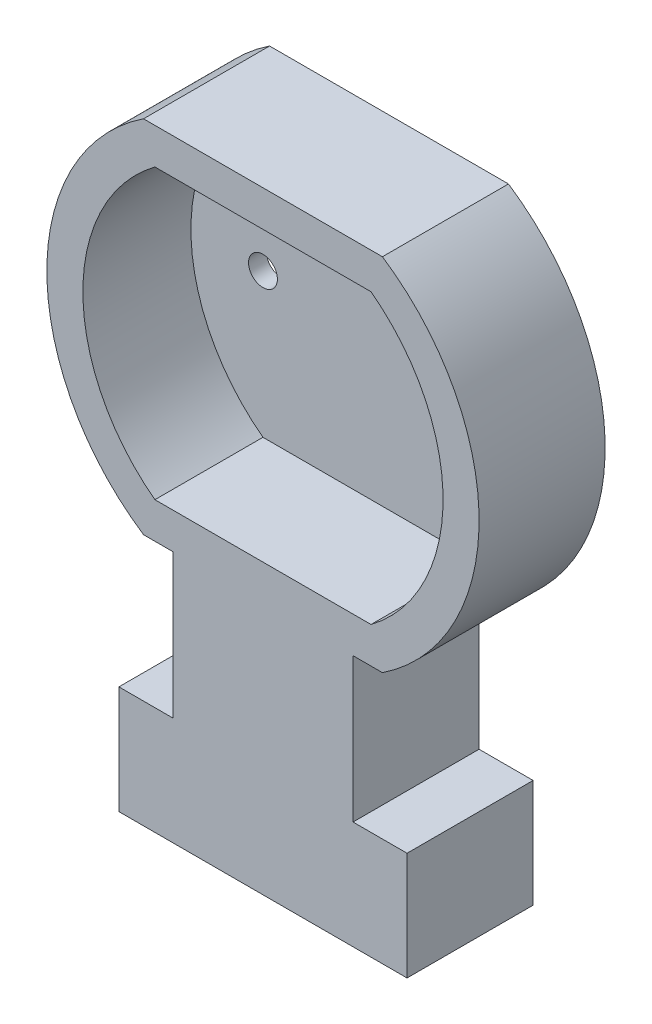
from build123d import *

# Parameters (mm, degrees)
BOSS_EXTRU_1_DEPTH      = 0.5
BOSS_EXTRU_2_START      = 3
BOSS_EXTRU_2_DEPTH      = 3
ESQUISSE1_4_R           = 0.4
ENL_V_MAT_EXTRU_1_DEPTH = 9.366600265
BOSS_EXTRU_3_DEPTH      = 3
BOSS_EXTRU_3_DEPTH_BACK = 0.5


with BuildPart() as part:
    # Esquisse1 → Boss.-Extru.1 (new body)
    with BuildSketch(Plane.XY):
        with BuildLine():
            Line((-3.31662479, 5), (3.31662479, 5))
            ThreePointArc((3.31662479, 5), (6, 0), (3.31662479, -5))
            Line((3.31662479, -5), (-3.31662479, -5))
            ThreePointArc((-3.31662479, -5), (-6, 0), (-3.31662479, 5))
        make_face()
    extrude(amount=-BOSS_EXTRU_1_DEPTH)

    # Esquisse1_3 → Boss.-Extru.2 (add)
    with BuildSketch(Plane.XY.offset(BOSS_EXTRU_2_START)):
        with BuildLine():
            Line((3.31662479, 5), (-3.31662479, 5))
            ThreePointArc((-3.31662479, 5), (-6, 0), (-3.31662479, -5))
            Line((-3.31662479, -5), (-2.5, -5))
            Line((-2.5, -5), (2.5, -5))
            Line((2.5, -5), (3.31662479, -5))
            ThreePointArc((3.31662479, -5), (6, 0), (3.31662479, 5))
        make_face()
        with BuildLine():
            ThreePointArc((-3, -4), (-5, 0), (-3, 4))
            Line((-3, 4), (3, 4))
            ThreePointArc((3, 4), (5, 0), (3, -4))
            Line((3, -4), (-3, -4))
        make_face(mode=Mode.SUBTRACT)
    extrude(amount=-BOSS_EXTRU_2_DEPTH)

    # Esquisse1_4 → Enl_v. mat.-Extru.1 (cut, through all)
    with BuildSketch(Plane.XY):
        with Locations((-3, 0)):
            Circle(ESQUISSE1_4_R)
        with Locations((3, 0)):
            Circle(ESQUISSE1_4_R)
    extrude(amount=-ENL_V_MAT_EXTRU_1_DEPTH, mode=Mode.SUBTRACT)

    # Esquisse1_5 → Boss.-Extru.3 (add, two sides: drawn at the far end of the back side and taken through both)
    with BuildSketch(Plane.XY.offset(-BOSS_EXTRU_3_DEPTH_BACK)):
        Polygon((2.5, -5), (-2.5, -5), (-2.5, -9), (-4, -9), (-4, -12), (4, -12), (4, -9), (2.5, -9), align=None)
    extrude(amount=BOSS_EXTRU_3_DEPTH + BOSS_EXTRU_3_DEPTH_BACK)


solid = part.part
